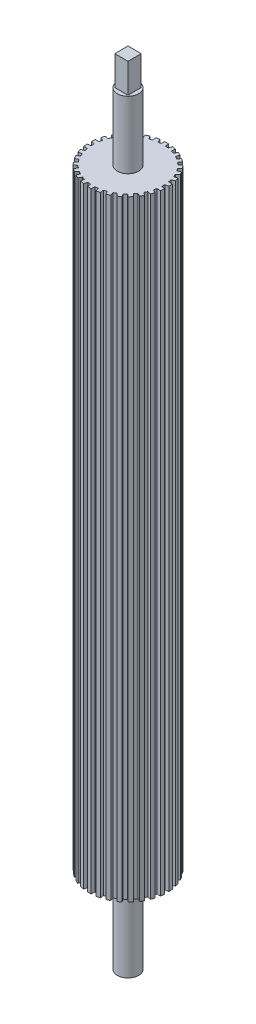
from build123d import *

# Parameters (mm, degrees)
BOSS_EXTRUDE1_DEPTH = 211.1375
SCALE2_SCALE_X      = 0.96
SCALE2_SCALE_Y      = 1
SCALE2_SCALE_Z      = 0.96
SKETCH3_R           = 3.68046
BOSS_EXTRUDE2_DEPTH = 23.20925
SKETCH4_R           = 3.68046
BOSS_EXTRUDE3_DEPTH = 29.55925
SKETCH6_W           = 4.572
SKETCH6_H           = 4.572
BOSS_EXTRUDE4_DEPTH = 10.16


with BuildPart() as part:
    # Sketch2 → Boss-Extrude1 (new body)
    with BuildSketch(Plane(origin=(0, 0, 0), x_dir=(1, 0, 0), z_dir=(0, 1, 0))):
        with BuildLine():
            Line((-0.775316452, 12.67631194), (-0.670254455, 13.953911959))
            ThreePointArc((-0.670254455, 13.953911959), (0, 13.97), (0.670254455, 13.953911959))
            Line((0.670254455, 13.953911959), (0.775316452, 12.67631194))
            ThreePointArc((0.775316452, 12.67631194), (1.327511483, 12.630428071), (1.877179521, 12.560501465))
            Line((1.877179521, 12.560501465), (2.245573641, 13.788339241))
            ThreePointArc((2.245573641, 13.788339241), (2.904526321, 13.664721982), (3.556789216, 13.509631767))
            Line((3.556789216, 13.509631767), (3.393927376, 12.238106756))
            ThreePointArc((3.393927376, 12.238106756), (3.924515829, 12.078417757), (4.447633742, 11.895736803))
            Line((4.447633742, 11.895736803), (5.063259395, 13.020149934))
            ThreePointArc((5.063259395, 13.020149934), (5.682110904, 12.762230043), (6.287875221, 12.474915839))
            Line((6.287875221, 12.474915839), (5.864207388, 11.265037581))
            ThreePointArc((5.864207388, 11.265037581), (6.35, 10.998522628), (6.823705026, 10.711071362))
            Line((6.823705026, 10.711071362), (7.659656416, 11.682917597))
            ThreePointArc((7.659656416, 11.682917597), (8.211359975, 11.301967411), (8.744150906, 10.894986229))
            Line((8.744150906, 10.894986229), (8.078193398, 9.799632209))
            ThreePointArc((8.078193398, 9.799632209), (8.497958701, 9.437939284), (8.901547657, 9.058280704))
            Line((8.901547657, 9.058280704), (9.921289697, 9.835085701))
            ThreePointArc((9.921289697, 9.835085701), (10.381733212, 9.347754571), (10.818265238, 8.83889344))
            Line((10.818265238, 8.83889344), (9.939123592, 7.905935885))
            ThreePointArc((9.939123592, 7.905935885), (10.274515829, 7.464872704), (10.59034994, 7.009599713))
            Line((10.59034994, 7.009599713), (11.749315011, 7.557413365))
            ThreePointArc((11.749315011, 7.557413365), (12.098374891, 6.985), (12.419569467, 6.396498594))
            Line((12.419569467, 6.396498594), (11.365666392, 5.666712226))
            ThreePointArc((11.365666392, 5.666712226), (11.602027312, 5.165555367), (11.816303113, 4.654565579))
            Line((11.816303113, 4.654565579), (13.063838879, 4.949445801))
            ThreePointArc((13.063838879, 4.949445801), (13.286259533, 4.316967411), (13.478078914, 3.674546066))
            Line((13.478078914, 3.674546066), (12.295475033, 3.179826051))
            ThreePointArc((12.295475033, 3.179826051), (12.422474529, 2.640478473), (12.52582714, 2.096104594))
            Line((12.52582714, 2.096104594), (13.807410301, 2.125163705))
            ThreePointArc((13.807410301, 2.125163705), (13.893470878, 1.460262632), (13.947531638, 0.791998242))
            Line((13.947531638, 0.791998242), (12.687912414, 0.55396622))
            ThreePointArc((12.687912414, 0.55396622), (12.7, 0), (12.687912414, -0.55396622))
            Line((12.687912414, -0.55396622), (13.947531638, -0.791998242))
            ThreePointArc((13.947531638, -0.791998242), (13.893470878, -1.460262632), (13.807410301, -2.125163705))
            Line((13.807410301, -2.125163705), (12.52582714, -2.096104594))
            ThreePointArc((12.52582714, -2.096104594), (12.422474529, -2.640478473), (12.295475033, -3.179826051))
            Line((12.295475033, -3.179826051), (13.478078914, -3.674546066))
            ThreePointArc((13.478078914, -3.674546066), (13.286259533, -4.316967411), (13.063838879, -4.949445801))
            Line((13.063838879, -4.949445801), (11.816303113, -4.654565579))
            ThreePointArc((11.816303113, -4.654565579), (11.602027312, -5.165555367), (11.365666392, -5.666712226))
            Line((11.365666392, -5.666712226), (12.419569467, -6.396498594))
            ThreePointArc((12.419569467, -6.396498594), (12.098374891, -6.985), (11.749315011, -7.557413365))
            Line((11.749315011, -7.557413365), (10.59034994, -7.009599713))
            ThreePointArc((10.59034994, -7.009599713), (10.274515829, -7.464872704), (9.939123592, -7.905935885))
            Line((9.939123592, -7.905935885), (10.818265238, -8.83889344))
            ThreePointArc((10.818265238, -8.83889344), (10.381733212, -9.347754571), (9.921289697, -9.835085701))
            Line((9.921289697, -9.835085701), (8.901547657, -9.058280704))
            ThreePointArc((8.901547657, -9.058280704), (8.497958701, -9.437939284), (8.078193398, -9.799632209))
            Line((8.078193398, -9.799632209), (8.744150906, -10.894986229))
            ThreePointArc((8.744150906, -10.894986229), (8.211359975, -11.301967411), (7.659656416, -11.682917597))
            Line((7.659656416, -11.682917597), (6.823705026, -10.711071362))
            ThreePointArc((6.823705026, -10.711071362), (6.35, -10.998522628), (5.864207388, -11.265037581))
            Line((5.864207388, -11.265037581), (6.287875221, -12.474915839))
            ThreePointArc((6.287875221, -12.474915839), (5.682110904, -12.762230043), (5.063259395, -13.020149934))
            Line((5.063259395, -13.020149934), (4.447633742, -11.895736803))
            ThreePointArc((4.447633742, -11.895736803), (3.924515829, -12.078417757), (3.393927376, -12.238106756))
            Line((3.393927376, -12.238106756), (3.556789216, -13.509631767))
            ThreePointArc((3.556789216, -13.509631767), (2.904526321, -13.664721982), (2.245573641, -13.788339241))
            Line((2.245573641, -13.788339241), (1.877179521, -12.560501465))
            ThreePointArc((1.877179521, -12.560501465), (1.327511483, -12.630428071), (0.775316452, -12.67631194))
            Line((0.775316452, -12.67631194), (0.670254455, -13.953911959))
            ThreePointArc((0.670254455, -13.953911959), (0, -13.97), (-0.670254455, -13.953911959))
            Line((-0.670254455, -13.953911959), (-0.775316452, -12.67631194))
            ThreePointArc((-0.775316452, -12.67631194), (-1.327511483, -12.630428071), (-1.877179521, -12.560501465))
            Line((-1.877179521, -12.560501465), (-2.245573641, -13.788339241))
            ThreePointArc((-2.245573641, -13.788339241), (-2.904526321, -13.664721982), (-3.556789216, -13.509631767))
            Line((-3.556789216, -13.509631767), (-3.393927376, -12.238106756))
            ThreePointArc((-3.393927376, -12.238106756), (-3.924515829, -12.078417757), (-4.447633742, -11.895736803))
            Line((-4.447633742, -11.895736803), (-5.063259395, -13.020149934))
            ThreePointArc((-5.063259395, -13.020149934), (-5.682110904, -12.762230043), (-6.287875221, -12.474915839))
            Line((-6.287875221, -12.474915839), (-5.864207388, -11.265037581))
            ThreePointArc((-5.864207388, -11.265037581), (-6.35, -10.998522628), (-6.823705026, -10.711071362))
            Line((-6.823705026, -10.711071362), (-7.659656416, -11.682917597))
            ThreePointArc((-7.659656416, -11.682917597), (-8.211359975, -11.301967411), (-8.744150906, -10.894986229))
            Line((-8.744150906, -10.894986229), (-8.078193398, -9.799632209))
            ThreePointArc((-8.078193398, -9.799632209), (-8.497958701, -9.437939284), (-8.901547657, -9.058280704))
            Line((-8.901547657, -9.058280704), (-9.921289697, -9.835085701))
            ThreePointArc((-9.921289697, -9.835085701), (-10.381733212, -9.347754571), (-10.818265238, -8.83889344))
            Line((-10.818265238, -8.83889344), (-9.939123592, -7.905935885))
            ThreePointArc((-9.939123592, -7.905935885), (-10.274515829, -7.464872704), (-10.59034994, -7.009599713))
            Line((-10.59034994, -7.009599713), (-11.749315011, -7.557413365))
            ThreePointArc((-11.749315011, -7.557413365), (-12.098374891, -6.985), (-12.419569467, -6.396498594))
            Line((-12.419569467, -6.396498594), (-11.365666392, -5.666712226))
            ThreePointArc((-11.365666392, -5.666712226), (-11.602027312, -5.165555367), (-11.816303113, -4.654565579))
            Line((-11.816303113, -4.654565579), (-13.063838879, -4.949445801))
            ThreePointArc((-13.063838879, -4.949445801), (-13.286259533, -4.316967411), (-13.478078914, -3.674546066))
            Line((-13.478078914, -3.674546066), (-12.295475033, -3.179826051))
            ThreePointArc((-12.295475033, -3.179826051), (-12.422474529, -2.640478473), (-12.52582714, -2.096104594))
            Line((-12.52582714, -2.096104594), (-13.807410301, -2.125163705))
            ThreePointArc((-13.807410301, -2.125163705), (-13.893470878, -1.460262632), (-13.947531638, -0.791998242))
            Line((-13.947531638, -0.791998242), (-12.687912414, -0.55396622))
            ThreePointArc((-12.687912414, -0.55396622), (-12.7, 0), (-12.687912414, 0.55396622))
            Line((-12.687912414, 0.55396622), (-13.947531638, 0.791998242))
            ThreePointArc((-13.947531638, 0.791998242), (-13.893470878, 1.460262632), (-13.807410301, 2.125163705))
            Line((-13.807410301, 2.125163705), (-12.52582714, 2.096104594))
            ThreePointArc((-12.52582714, 2.096104594), (-12.422474529, 2.640478473), (-12.295475033, 3.179826051))
            Line((-12.295475033, 3.179826051), (-13.478078914, 3.674546066))
            ThreePointArc((-13.478078914, 3.674546066), (-13.286259533, 4.316967411), (-13.063838879, 4.949445801))
            Line((-13.063838879, 4.949445801), (-11.816303113, 4.654565579))
            ThreePointArc((-11.816303113, 4.654565579), (-11.602027312, 5.165555367), (-11.365666392, 5.666712226))
            Line((-11.365666392, 5.666712226), (-12.419569467, 6.396498594))
            ThreePointArc((-12.419569467, 6.396498594), (-12.098374891, 6.985), (-11.749315011, 7.557413365))
            Line((-11.749315011, 7.557413365), (-10.59034994, 7.009599713))
            ThreePointArc((-10.59034994, 7.009599713), (-10.274515829, 7.464872704), (-9.939123592, 7.905935885))
            Line((-9.939123592, 7.905935885), (-10.818265238, 8.83889344))
            ThreePointArc((-10.818265238, 8.83889344), (-10.381733212, 9.347754571), (-9.921289697, 9.835085701))
            Line((-9.921289697, 9.835085701), (-8.901547657, 9.058280704))
            ThreePointArc((-8.901547657, 9.058280704), (-8.497958701, 9.437939284), (-8.078193398, 9.799632209))
            Line((-8.078193398, 9.799632209), (-8.744150906, 10.894986229))
            ThreePointArc((-8.744150906, 10.894986229), (-8.211359975, 11.301967411), (-7.659656416, 11.682917597))
            Line((-7.659656416, 11.682917597), (-6.823705026, 10.711071362))
            ThreePointArc((-6.823705026, 10.711071362), (-6.35, 10.998522628), (-5.864207388, 11.265037581))
            Line((-5.864207388, 11.265037581), (-6.287875221, 12.474915839))
            ThreePointArc((-6.287875221, 12.474915839), (-5.682110904, 12.762230043), (-5.063259395, 13.020149934))
            Line((-5.063259395, 13.020149934), (-4.447633742, 11.895736803))
            ThreePointArc((-4.447633742, 11.895736803), (-3.924515829, 12.078417757), (-3.393927376, 12.238106756))
            Line((-3.393927376, 12.238106756), (-3.556789216, 13.509631767))
            ThreePointArc((-3.556789216, 13.509631767), (-2.904526321, 13.664721982), (-2.245573641, 13.788339241))
            Line((-2.245573641, 13.788339241), (-1.877179521, 12.560501465))
            ThreePointArc((-1.877179521, 12.560501465), (-1.327511483, 12.630428071), (-0.775316452, 12.67631194))
        make_face()
    extrude(amount=BOSS_EXTRUDE1_DEPTH)


with BuildPart() as part_1:
    # Scale2: scaled about (0, 105.56875, 0)
    add(part.part.scale((SCALE2_SCALE_X, SCALE2_SCALE_Y, SCALE2_SCALE_Z), about=(0, 105.56875, 0)))

    # Sketch3 → Boss-Extrude2 (add)
    with BuildSketch(Plane(origin=(0, 211.1375, 0), x_dir=(1, 0, 0), z_dir=(0, 1, 0))):
        Circle(SKETCH3_R)
    extrude(amount=BOSS_EXTRUDE2_DEPTH)

    # Sketch4 → Boss-Extrude3 (add)
    with BuildSketch(Plane(origin=(0, 0, 0), x_dir=(-1, 0, 0), z_dir=(0, -1, 0))):
        Circle(SKETCH4_R)
    extrude(amount=BOSS_EXTRUDE3_DEPTH)

    # Sketch6 → Boss-Extrude4 (add)
    with BuildSketch(Plane(origin=(0, 234.34675, 0), x_dir=(1, 0, 0), z_dir=(0, 1, 0))):
        Rectangle(SKETCH6_W, SKETCH6_H)
    extrude(amount=BOSS_EXTRUDE4_DEPTH)


solid = part_1.part
